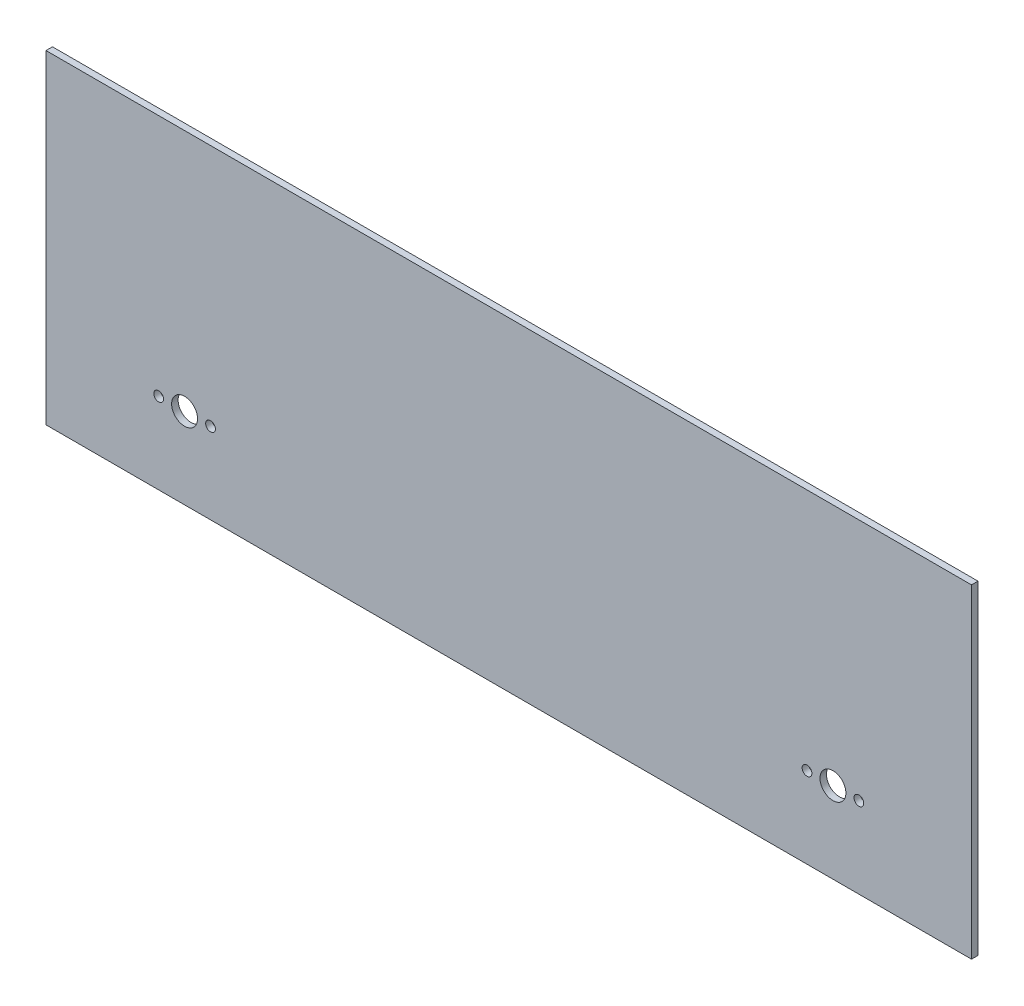
from build123d import *

# Parameters (mm, degrees)
SKETCH1_W           = 285.5
SKETCH1_H           = 100
SKETCH1_R           = 4
SKETCH1_R_2         = 1.5
BOSS_EXTRUDE1_DEPTH = 2


with BuildPart() as part:
    # Sketch1 → Boss-Extrude1 (new body)
    with BuildSketch(Plane.XY):
        Rectangle(SKETCH1_W, SKETCH1_H)
        with Locations((-100, -25)):
            Circle(SKETCH1_R, mode=Mode.SUBTRACT)
        with Locations((-92, -25)):
            Circle(SKETCH1_R_2, mode=Mode.SUBTRACT)
        with Locations((-108, -25)):
            Circle(SKETCH1_R_2, mode=Mode.SUBTRACT)
        with Locations((108, -25)):
            Circle(SKETCH1_R_2, mode=Mode.SUBTRACT)
        with Locations((92, -25)):
            Circle(SKETCH1_R_2, mode=Mode.SUBTRACT)
        with Locations((100, -25)):
            Circle(SKETCH1_R, mode=Mode.SUBTRACT)
    extrude(amount=BOSS_EXTRUDE1_DEPTH)


solid = part.part
